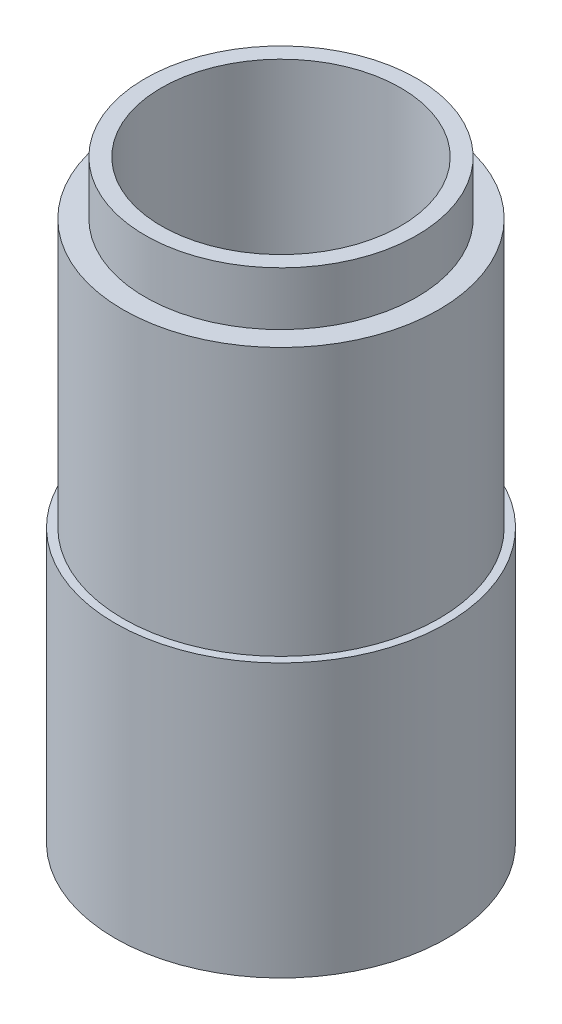
from build123d import *


with BuildPart() as part:
    # Sketch1 → Revolve1 (revolve)
    with BuildSketch(Plane.XY):
        Polygon((9.655, 0), (15.5, 0), (15.5, 25.5), (14.75, 25.5), (14.75, 50.5), (12.7, 50.5), (12.7, 55.5), (11.185, 55.5), (11.185, 5), (9.655, 5), align=None)
    revolve(axis=Axis((0, 0, 0), (0, 1, 0)))


solid = part.part
